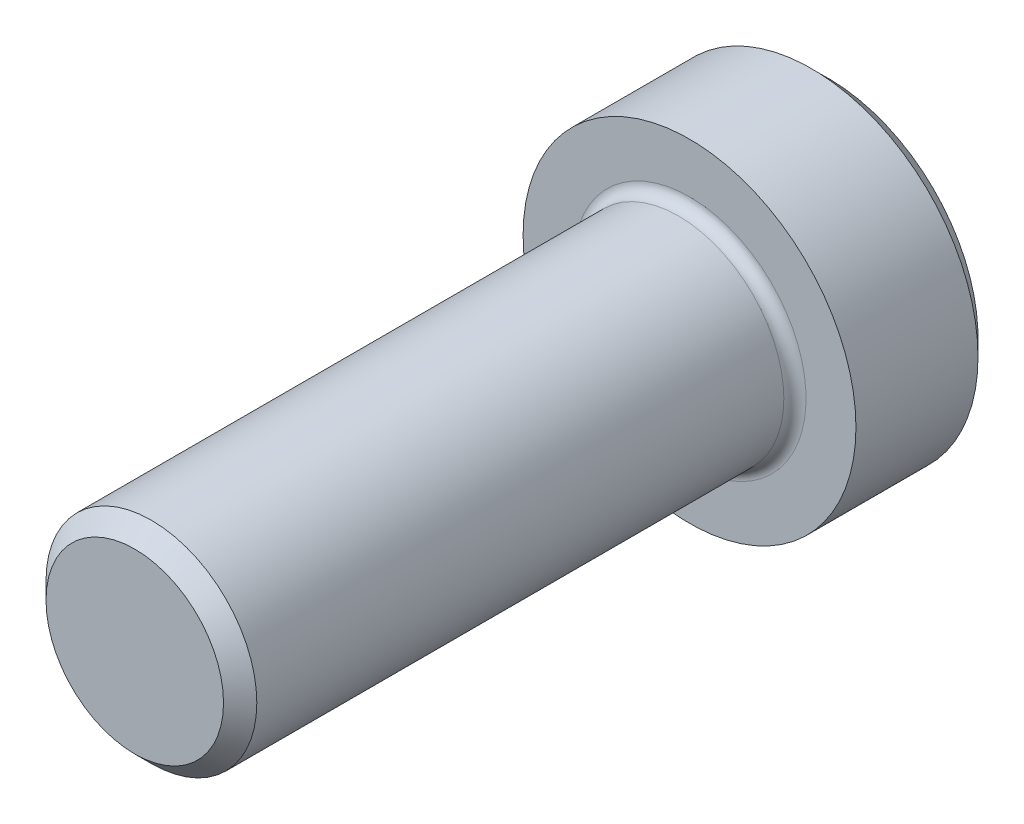
from build123d import *

# Parameters (mm, degrees)
SKETCH1_R           = 0.19
BOSS_EXTRUDE1_DEPTH = 1
SKETCH2_R           = 0.3
BOSS_EXTRUDE2_DEPTH = 0.25
CHAMFER1_SIZE       = 0.03
FILLET1_R           = 0.02
CUT_EXTRUDE1_DEPTH  = 0.15
SKETCH4_R           = 0.175
CUT_EXTRUDE2_DEPTH  = 0.1
CUT_EXTRUDE2_TAPER  = 60


with BuildPart() as part:
    # Sketch1 → Boss-Extrude1 (new body)
    with BuildSketch(Plane.XY):
        Circle(SKETCH1_R)
    extrude(amount=BOSS_EXTRUDE1_DEPTH)

    # Sketch2 → Boss-Extrude2 (add)
    with BuildSketch(Plane(origin=(0, 0, 0), x_dir=(-1, 0, 0), z_dir=(0, 0, -1))):
        Circle(SKETCH2_R)
    extrude(amount=BOSS_EXTRUDE2_DEPTH)

    # Chamfer1
    chamfer1_edges = [part.edges().sort_by_distance(p)[0] for p in [
        (-0.19, 0, 1),
        (0.3, 0, -0.25),
    ]]
    chamfer(chamfer1_edges, length=CHAMFER1_SIZE)

    # Fillet1
    fillet1_edges = [part.edges().sort_by_distance(p)[0] for p in [
        (-0.19, 0, 0),
    ]]
    fillet(fillet1_edges, radius=FILLET1_R)

    # Sketch3 → Cut-Extrude1 (cut)
    with BuildSketch(Plane(origin=(0, 0, -0.25), x_dir=(-1, 0, 0), z_dir=(0, 0, -1))):
        Polygon((0.202072594, 0), (0.101036297, 0.175), (-0.101036297, 0.175), (-0.202072594, 0), (-0.101036297, -0.175), (0.101036297, -0.175), align=None)
    extrude(amount=-CUT_EXTRUDE1_DEPTH, mode=Mode.SUBTRACT)

    # Sketch4 → Cut-Extrude2 (cut)
    with BuildSketch(Plane(origin=(0, 0, -0.1), x_dir=(-1, 0, 0), z_dir=(0, 0, -1))):
        Circle(SKETCH4_R)
    extrude(amount=-CUT_EXTRUDE2_DEPTH, taper=CUT_EXTRUDE2_TAPER, mode=Mode.SUBTRACT)


solid = part.part
